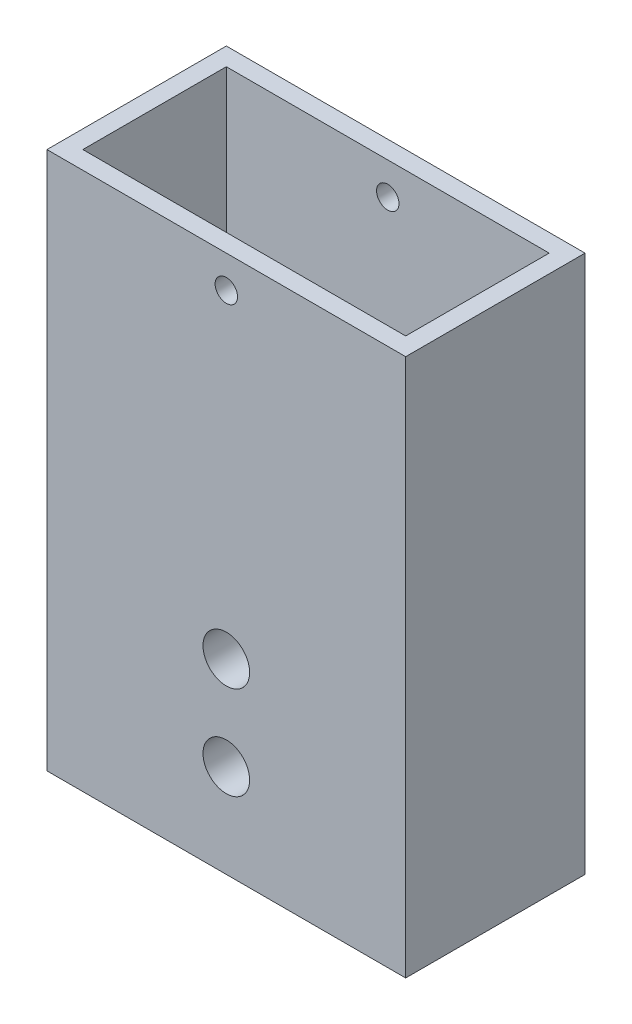
from build123d import *

# Parameters (mm, degrees)
SKETCH1_W           = 50.8
SKETCH1_H           = 76.2
SKETCH1_R           = 3.302
BOSS_EXTRUDE1_DEPTH = 25.4
SKETCH2_W           = 45.72
SKETCH2_H           = 20.32
CUT_EXTRUDE1_DEPTH  = 38.1
SKETCH3_R           = 1.5875
CUT_EXTRUDE2_DEPTH  = 26.4


with BuildPart() as part:
    # Sketch1 → Boss-Extrude1 (new body)
    with BuildSketch(Plane.XY):
        with Locations((25.4, 38.1)):
            Rectangle(SKETCH1_W, SKETCH1_H)
        with Locations((25.4, 13.208)):
            Circle(SKETCH1_R, mode=Mode.SUBTRACT)
        with Locations((25.4, 26.416)):
            Circle(SKETCH1_R, mode=Mode.SUBTRACT)
    extrude(amount=BOSS_EXTRUDE1_DEPTH)

    # Sketch2 → Cut-Extrude1 (cut)
    with BuildSketch(Plane(origin=(0, 76.2, 0), x_dir=(1, 0, 0), z_dir=(0, 1, 0))):
        with Locations((25.4, -12.7)):
            Rectangle(SKETCH2_W, SKETCH2_H)
    extrude(amount=-CUT_EXTRUDE1_DEPTH, mode=Mode.SUBTRACT)

    # Sketch3 → Cut-Extrude2 (cut, through all)
    with BuildSketch(Plane.XY.offset(25.4)):
        with Locations((25.4, 71.628)):
            Circle(SKETCH3_R)
    extrude(amount=-CUT_EXTRUDE2_DEPTH, mode=Mode.SUBTRACT)


solid = part.part
